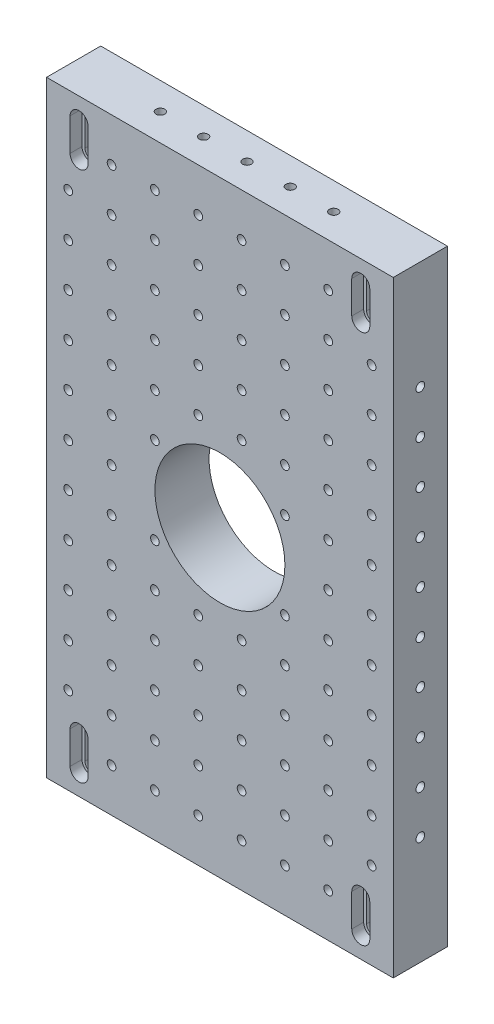
from build123d import *

# Parameters (mm, degrees)
SKETCH1_W               = 203.2
SKETCH1_H               = 355.6
SKETCH1_R               = 38.1
BOSS_EXTRUDE1_DEPTH     = 31.75
CUT_EXTRUDE1_START      = -12.7
CUT_EXTRUDE1_DEPTH      = 19.05
LPATTERN1_COUNT         = 2
LPATTERN1_PITCH         = 311.15
LPATTERN1_COUNT_DIR2    = 2
LPATTERN1_PITCH_DIR2    = 165.1
F_1_4_20_TAPPED_HOLE1_D = 5.1054
LPATTERN2_COUNT         = 12
LPATTERN2_PITCH         = 25.4
LPATTERN2_COUNT_DIR2    = 8
LPATTERN2_PITCH_DIR2    = 25.4
LPATTERN3_COUNT         = 2
LPATTERN3_PITCH         = 25.4
LPATTERN3_COUNT_DIR2    = 8
LPATTERN3_PITCH_DIR2    = 25.4
LPATTERN4_COUNT         = 10
LPATTERN4_PITCH         = 25.4
LPATTERN5_COUNT         = 10
LPATTERN5_PITCH         = 25.4
LPATTERN6_COUNT         = 5
LPATTERN6_PITCH         = 25.4
LPATTERN7_COUNT         = 5
LPATTERN7_PITCH         = 25.4


with BuildPart() as part:
    # Sketch1 → Boss-Extrude1 (new body)
    with BuildSketch(Plane.XY):
        with Locations((101.6, 177.8)):
            Rectangle(SKETCH1_W, SKETCH1_H)
        with Locations((101.6, 177.8)):
            Circle(SKETCH1_R, mode=Mode.SUBTRACT)
    extrude(amount=BOSS_EXTRUDE1_DEPTH)

    # Sketch2 → Cut-Extrude1 (cut)
    with BuildSketch(Plane.XZ.offset(CUT_EXTRUDE1_START)):
        Polygon((13.7668, 31.75), (13.7668, 24.765), (15.4813, 24.765), (15.4813, 0), (22.6187, 0), (22.6187, 24.765), (24.3332, 24.765), (24.3332, 31.75), align=None)
    cut_extrude1 = extrude(amount=-CUT_EXTRUDE1_DEPTH, mode=Mode.SUBTRACT)

    # Sketch4 → Cut-Revolve3 (revolve, cut)
    with BuildSketch(Plane.XZ.offset(-31.75)):
        Polygon((19.05, 0), (19.05, 31.75), (13.7668, 31.75), (13.7668, 24.765), (15.4813, 24.765), (15.4813, 0), align=None)
    cut_revolve3 = revolve(axis=Axis((19.05, 31.75, 0), (0, 0, 1)), mode=Mode.SUBTRACT)

    # Sketch6 → Cut-Revolve4 (revolve, cut)
    with BuildSketch(Plane(origin=(0, 12.7, 0), x_dir=(1, 0, 0), z_dir=(0, 1, 0))):
        Polygon((19.05, 0), (19.05, -31.75), (24.3332, -31.75), (24.3332, -24.765), (22.6187, -24.765), (22.6187, 0), align=None)
    cut_revolve4 = revolve(axis=Axis((19.05, 12.7, 0), (0, 0, 1)), mode=Mode.SUBTRACT)

    # LPattern1: Cut-Extrude1, Cut-Revolve3, Cut-Revolve4 2 × 2
    with Locations(*[(j * LPATTERN1_PITCH_DIR2, i * LPATTERN1_PITCH, 0) for i in range(LPATTERN1_COUNT) for j in range(LPATTERN1_COUNT_DIR2) if (i, j) != (0, 0)]):
        add(cut_extrude1, mode=Mode.SUBTRACT)
        add(cut_revolve3, mode=Mode.SUBTRACT)
        add(cut_revolve4, mode=Mode.SUBTRACT)

    # 1/4-20 Tapped Hole1 (through all)
    with Locations(Plane.XY.offset(31.75)):
        with Locations((12.7, 50.8)):
            f_1_4_20_tapped_hole1 = Hole(F_1_4_20_TAPPED_HOLE1_D / 2)

    # LPattern2: 1_4-20 Tapped Hole1 12 × 8, 4 skipped
    with Locations(*[(j * LPATTERN2_PITCH_DIR2, i * LPATTERN2_PITCH, 0) for i in range(LPATTERN2_COUNT) for j in range(LPATTERN2_COUNT_DIR2) if (i, j) not in ((0, 0), (5, 2), (5, 5), (11, 0), (11, 7))]):
        add(f_1_4_20_tapped_hole1, mode=Mode.SUBTRACT)

    # LPattern3: 1_4-20 Tapped Hole1 2 × 8, 2 skipped
    with Locations(*[(j * LPATTERN3_PITCH_DIR2, -i * LPATTERN3_PITCH, 0) for i in range(LPATTERN3_COUNT) for j in range(LPATTERN3_COUNT_DIR2) if (i, j) not in ((0, 0), (1, 0), (1, 7))]):
        add(f_1_4_20_tapped_hole1, mode=Mode.SUBTRACT)

    # Sketch9 → 1/4-20 Tapped Hole2 (revolve, cut)
    with BuildSketch(Plane(origin=(0, 292.1, 15.875), x_dir=(0, 0, 1), z_dir=(0, 1, 0))):
        Polygon((0, 0), (0, 33.283816902), (2.5527, 31.75), (2.5527, 0), align=None)
    f_1_4_20_tapped_hole2 = revolve(axis=Axis((-6.35, 292.1, 15.875), (1, 0, 0)), mode=Mode.SUBTRACT)

    # LPattern4: 1/4-20 Tapped Hole2 ×10
    with Locations(*[(0, -i * LPATTERN4_PITCH, 0) for i in range(1, LPATTERN4_COUNT)]):
        add(f_1_4_20_tapped_hole2, mode=Mode.SUBTRACT)

    # Sketch14 → 1/4-20 Tapped Hole3 (revolve, cut)
    with BuildSketch(Plane(origin=(203.2, 63.5, 15.875), x_dir=(0, 0, -1), z_dir=(0, 1, 0))):
        Polygon((0, 0), (0, 33.283816902), (2.5527, 31.75), (2.5527, 0), align=None)
    f_1_4_20_tapped_hole3 = revolve(axis=Axis((209.55, 63.5, 15.875), (-1, 0, 0)), mode=Mode.SUBTRACT)

    # LPattern5: 1/4-20 Tapped Hole3 ×10
    with Locations(*[(0, i * LPATTERN5_PITCH, 0) for i in range(1, LPATTERN5_COUNT)]):
        add(f_1_4_20_tapped_hole3, mode=Mode.SUBTRACT)

    # Sketch18 → 1/4-20 Tapped Hole4 (revolve, cut)
    with BuildSketch(Plane(origin=(50.8, 0, 15.875), x_dir=(0, 0, -1), z_dir=(1, 0, 0))):
        Polygon((0, 0), (0, 33.283816902), (2.5527, 31.75), (2.5527, 0), align=None)
    f_1_4_20_tapped_hole4 = revolve(axis=Axis((50.8, -6.35, 15.875), (0, 1, 0)), mode=Mode.SUBTRACT)

    # LPattern6: 1/4-20 Tapped Hole4 ×5
    with Locations(*[(i * LPATTERN6_PITCH, 0, 0) for i in range(1, LPATTERN6_COUNT)]):
        add(f_1_4_20_tapped_hole4, mode=Mode.SUBTRACT)

    # Sketch22 → 1/4-20 Tapped Hole5 (revolve, cut)
    with BuildSketch(Plane(origin=(152.4, 355.6, 15.875), x_dir=(0, 0, 1), z_dir=(1, 0, 0))):
        Polygon((0, 0), (0, 33.283816902), (2.5527, 31.75), (2.5527, 0), align=None)
    f_1_4_20_tapped_hole5 = revolve(axis=Axis((152.4, 361.95, 15.875), (0, -1, 0)), mode=Mode.SUBTRACT)

    # LPattern7: 1/4-20 Tapped Hole5 ×5
    with Locations(*[(-i * LPATTERN7_PITCH, 0, 0) for i in range(1, LPATTERN7_COUNT)]):
        add(f_1_4_20_tapped_hole5, mode=Mode.SUBTRACT)


solid = part.part
